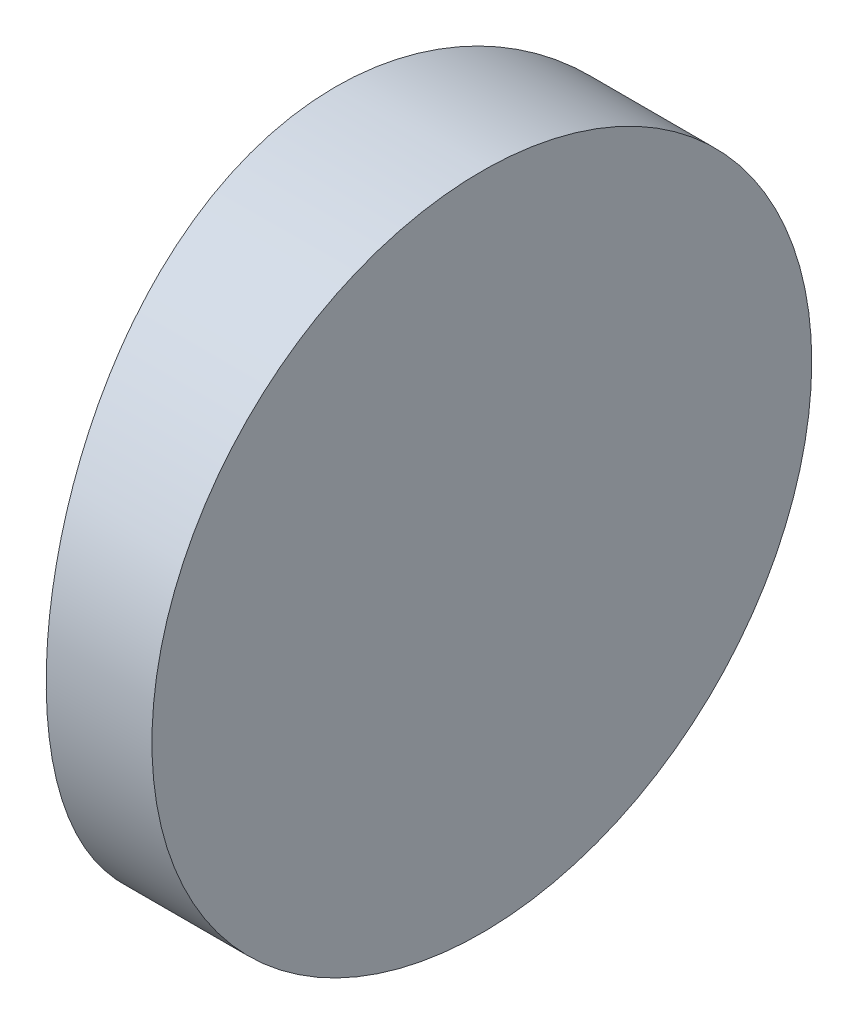
from build123d import *

# Parameters (mm, degrees)
EXTRUDE_1_DEPTH     = 12.5
CUT_EXTRUDE_8_DEPTH = 12.7


with BuildPart() as part:
    # 草图1 → 凸台-拉伸1 (new body)
    with BuildSketch(Plane(origin=(0, 0, 0), x_dir=(1, 0, 0), z_dir=(0, 1, 0))):
        with BuildLine():
            Line((-20.727857679, 6.25), (-18.724795665, 6.25))
            Line((-18.724795665, 6.25), (-18.724795665, -6.25))
            Line((-18.724795665, -6.25), (-20.727857679, -6.25))
            ThreePointArc((-20.727857679, -6.25), (-21.494795665, 0), (-20.727857679, 6.25))
        make_face()
    extrude(amount=EXTRUDE_1_DEPTH)

    # 草图2 → 切除-拉伸8 (cut)
    with BuildSketch(Plane(origin=(-18.724795665, 0, 0), x_dir=(0, 0, -1), z_dir=(1, 0, 0))):
        with BuildLine():
            Line((-6.25, 12.5), (-6.25, 6.25))
            ThreePointArc((-6.25, 6.25), (-4.419417382, 10.669417382), (0, 12.5))
            Line((0, 12.5), (-6.25, 12.5))
        make_face()
        with BuildLine():
            ThreePointArc((0, 12.5), (4.419417382, 10.669417382), (6.25, 6.25))
            Line((6.25, 6.25), (6.25, 12.5))
            Line((6.25, 12.5), (0, 12.5))
        make_face()
        with BuildLine():
            ThreePointArc((6.25, 6.25), (4.419417382, 1.830582618), (0, 0))
            Line((0, 0), (6.25, 0))
            Line((6.25, 0), (6.25, 6.25))
        make_face()
        with BuildLine():
            Line((-6.25, 6.25), (-6.25, 0))
            Line((-6.25, 0), (0, 0))
            ThreePointArc((0, 0), (-4.419417382, 1.830582618), (-6.25, 6.25))
        make_face()
    extrude(amount=-CUT_EXTRUDE_8_DEPTH, mode=Mode.SUBTRACT)


solid = part.part
